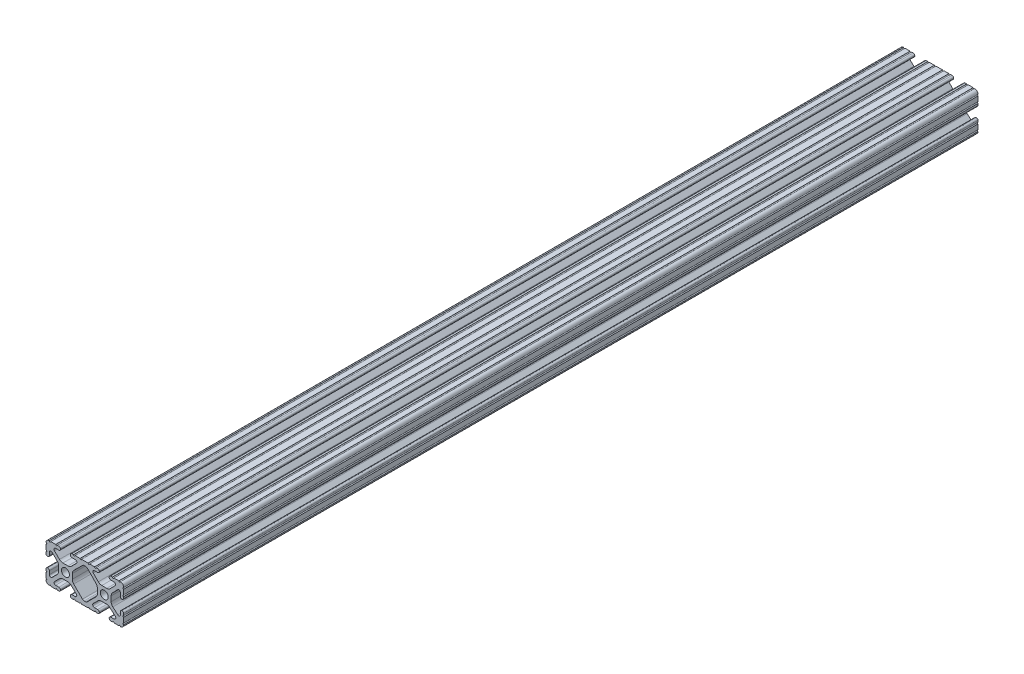
from build123d import *

# Parameters (mm, degrees)
SKETCH1_R               = 2.6035
BOSS_EXTRUDE1_DEPTH     = 279.4
SKETCH2_R               = 3.175
CUT_EXTRUDE1_DEPTH      = 9.2042
CUT_EXTRUDE1_DEPTH_BACK = 18.1958


with BuildPart() as part:
    # Sketch1 → Boss-Extrude1 (new body, symmetric)
    with BuildSketch(Plane.XY):
        with BuildLine():
            Line((18.01710265, 12.7), (16.98745015, 12.7))
            ThreePointArc((16.98745015, 12.7), (16.245730386, 12.392769614), (15.9385, 11.65104985))
            Line((15.9385, 11.65104985), (15.9385, 11.53922))
            ThreePointArc((15.9385, 11.53922), (16.245750844, 10.797450844), (16.98752, 10.4902))
            Line((16.98752, 10.4902), (19.116384363, 10.4902))
            ThreePointArc((19.116384363, 10.4902), (20.052502933, 9.869096983), (19.844087081, 8.765172272))
            Line((19.844087081, 8.765172272), (16.618993479, 5.455112286))
            ThreePointArc((16.618993479, 5.455112286), (15.578994274, 4.745442459), (14.344932584, 4.4958))
            Line((14.344932584, 4.4958), (11.083317835, 4.4958))
            ThreePointArc((11.083317835, 4.4958), (9.854330953, 4.743306833), (8.816955189, 5.447238587))
            Line((8.816955189, 5.447238587), (5.564154119, 8.762652677))
            ThreePointArc((5.564154119, 8.762652677), (5.352591412, 9.867473037), (6.289393385, 10.4902))
            Line((6.289393385, 10.4902), (8.41248, 10.4902))
            ThreePointArc((8.41248, 10.4902), (9.154249156, 10.797450844), (9.4615, 11.53922))
            Line((9.4615, 11.53922), (9.4615, 11.65104985))
            ThreePointArc((9.4615, 11.65104985), (9.154269614, 12.392769614), (8.41254985, 12.7))
            Line((8.41254985, 12.7), (7.38288465, 12.7))
            ThreePointArc((7.38288465, 12.7), (6.87488465, 12.192), (6.36688465, 12.7))
            Line((6.36688465, 12.7), (3.14958095, 12.7))
            ThreePointArc((3.14958095, 12.7), (2.64158095, 12.192), (2.13358095, 12.7))
            Line((2.13358095, 12.7), (-2.13358095, 12.7))
            ThreePointArc((-2.13358095, 12.7), (-2.64158095, 12.192), (-3.14958095, 12.7))
            Line((-3.14958095, 12.7), (-6.36689735, 12.7))
            ThreePointArc((-6.36689735, 12.7), (-6.87489735, 12.192), (-7.38289735, 12.7))
            Line((-7.38289735, 12.7), (-8.41254985, 12.7))
            ThreePointArc((-8.41254985, 12.7), (-9.154269614, 12.392769614), (-9.4615, 11.65104985))
            Line((-9.4615, 11.65104985), (-9.4615, 11.53922))
            ThreePointArc((-9.4615, 11.53922), (-9.154249156, 10.797450844), (-8.41248, 10.4902))
            Line((-8.41248, 10.4902), (-6.283641037, 10.4902))
            ThreePointArc((-6.283641037, 10.4902), (-5.297291557, 9.829633109), (-5.532576693, 8.666071843))
            Line((-5.532576693, 8.666071843), (-8.809985098, 5.416263103))
            ThreePointArc((-8.809985098, 5.416263103), (-9.836720513, 4.734920264), (-11.045536121, 4.4958))
            Line((-11.045536121, 4.4958), (-14.354463879, 4.4958))
            ThreePointArc((-14.354463879, 4.4958), (-15.563279487, 4.734920264), (-16.590014902, 5.416263103))
            Line((-16.590014902, 5.416263103), (-19.867423307, 8.666071843))
            ThreePointArc((-19.867423307, 8.666071843), (-20.102708443, 9.829633109), (-19.116358963, 10.4902))
            Line((-19.116358963, 10.4902), (-16.98752, 10.4902))
            ThreePointArc((-16.98752, 10.4902), (-16.245750844, 10.797450844), (-15.9385, 11.53922))
            Line((-15.9385, 11.53922), (-15.9385, 11.65104985))
            ThreePointArc((-15.9385, 11.65104985), (-16.245730386, 12.392769614), (-16.98745015, 12.7))
            Line((-16.98745015, 12.7), (-18.01711535, 12.7))
            ThreePointArc((-18.01711535, 12.7), (-18.52511535, 12.192), (-19.03311535, 12.7))
            Line((-19.03311535, 12.7), (-22.2504, 12.7))
            ThreePointArc((-22.2504, 12.7), (-22.758323491, 12.192000006), (-23.266399977, 12.699846982))
            ThreePointArc((-23.266399977, 12.699846982), (-24.782522516, 12.082522516), (-25.399846982, 10.566399977))
            ThreePointArc((-25.399846982, 10.566399977), (-24.892000006, 10.058323491), (-25.4, 9.5504))
            Line((-25.4, 9.5504), (-25.4, 6.3330836))
            ThreePointArc((-25.4, 6.3330836), (-24.892, 5.8250836), (-25.4, 5.3170836))
            Line((-25.4, 5.3170836), (-25.4, 4.237520184))
            ThreePointArc((-25.4, 4.237520184), (-25.107393763, 3.531106237), (-24.400979816, 3.2385))
            Line((-24.400979816, 3.2385), (-24.23922, 3.2385))
            ThreePointArc((-24.23922, 3.2385), (-23.497450844, 3.545750844), (-23.1902, 4.28752))
            Line((-23.1902, 4.28752), (-23.1902, 6.334741132))
            ThreePointArc((-23.1902, 6.334741132), (-22.556026952, 7.286023527), (-21.434002553, 7.066535717))
            Line((-21.434002553, 7.066535717), (-18.147950853, 3.808156468))
            ThreePointArc((-18.147950853, 3.808156468), (-17.452759693, 2.774838327), (-17.208501877, 1.553619571))
            Line((-17.208501877, 1.553619571), (-17.208501877, -1.695179196))
            ThreePointArc((-17.208501877, -1.695179196), (-17.450738657, -2.911536421), (-18.140486065, -3.942289578))
            Line((-18.140486065, -3.942289578), (-21.431579576, -7.227386226))
            ThreePointArc((-21.431579576, -7.227386226), (-22.55444896, -7.449940594), (-23.1902, -6.498002195))
            Line((-23.1902, -6.498002195), (-23.1902, -4.28752))
            ThreePointArc((-23.1902, -4.28752), (-23.497450844, -3.545750844), (-24.23922, -3.2385))
            Line((-24.23922, -3.2385), (-24.35098, -3.2385))
            ThreePointArc((-24.35098, -3.2385), (-25.092749156, -3.545750844), (-25.4, -4.28752))
            Line((-25.4, -4.28752), (-25.4, -5.3171344))
            ThreePointArc((-25.4, -5.3171344), (-24.892, -5.8251344), (-25.4, -6.3331344))
            Line((-25.4, -6.3331344), (-25.4, -9.5504))
            ThreePointArc((-25.4, -9.5504), (-24.892000006, -10.058323491), (-25.399846982, -10.566399977))
            ThreePointArc((-25.399846982, -10.566399977), (-24.782522516, -12.082522516), (-23.266399977, -12.699846982))
            ThreePointArc((-23.266399977, -12.699846982), (-22.758323491, -12.192000006), (-22.2504, -12.7))
            Line((-22.2504, -12.7), (-19.03308995, -12.7))
            ThreePointArc((-19.03308995, -12.7), (-18.52508995, -12.192), (-18.01708995, -12.7))
            Line((-18.01708995, -12.7), (-16.9874692, -12.7))
            ThreePointArc((-16.9874692, -12.7), (-16.245700044, -12.392749156), (-15.9384492, -11.65098))
            Line((-15.9384492, -11.65098), (-15.9384492, -11.53922))
            ThreePointArc((-15.9384492, -11.53922), (-16.245700044, -10.797450844), (-16.9874692, -10.4902))
            Line((-16.9874692, -10.4902), (-19.116358963, -10.4902))
            ThreePointArc((-19.116358963, -10.4902), (-20.055197748, -9.862578342), (-19.834124023, -8.755124678))
            Line((-19.834124023, -8.755124678), (-16.49660751, -5.423689618))
            ThreePointArc((-16.49660751, -5.423689618), (-15.467274017, -4.736928798), (-14.253591699, -4.4958))
            Line((-14.253591699, -4.4958), (-11.146408301, -4.4958))
            ThreePointArc((-11.146408301, -4.4958), (-9.932725983, -4.736928798), (-8.90339249, -5.423689618))
            Line((-8.90339249, -5.423689618), (-5.565875977, -8.755124678))
            ThreePointArc((-5.565875977, -8.755124678), (-5.344802252, -9.862578342), (-6.283641037, -10.4902))
            Line((-6.283641037, -10.4902), (-8.4125308, -10.4902))
            ThreePointArc((-8.4125308, -10.4902), (-9.154299956, -10.797450844), (-9.4615508, -11.53922))
            Line((-9.4615508, -11.53922), (-9.4615508, -11.65098))
            ThreePointArc((-9.4615508, -11.65098), (-9.154299956, -12.392749156), (-8.4125308, -12.7))
            Line((-8.4125308, -12.7), (-7.38287195, -12.7))
            ThreePointArc((-7.38287195, -12.7), (-6.87487195, -12.192), (-6.36687195, -12.7))
            Line((-6.36687195, -12.7), (-3.14960635, -12.7))
            ThreePointArc((-3.14960635, -12.7), (-2.64160635, -12.192), (-2.13360635, -12.7))
            Line((-2.13360635, -12.7), (2.13360635, -12.7))
            ThreePointArc((2.13360635, -12.7), (2.64159365, -12.1920127), (3.14958095, -12.7))
            Line((3.14958095, -12.7), (6.36691005, -12.7))
            ThreePointArc((6.36691005, -12.7), (6.87491005, -12.192), (7.38291005, -12.7))
            Line((7.38291005, -12.7), (8.4125308, -12.7))
            ThreePointArc((8.4125308, -12.7), (9.154299956, -12.392749156), (9.4615508, -11.65098))
            Line((9.4615508, -11.65098), (9.4615508, -11.53922))
            ThreePointArc((9.4615508, -11.53922), (9.154299956, -10.797450844), (8.4125308, -10.4902))
            Line((8.4125308, -10.4902), (6.289393385, -10.4902))
            ThreePointArc((6.289393385, -10.4902), (5.231590322, -9.783049717), (5.480677245, -8.535265862))
            Line((5.480677245, -8.535265862), (8.597933595, -5.423689618))
            ThreePointArc((8.597933595, -5.423689618), (9.627267088, -4.736928798), (10.840949406, -4.4958))
            Line((10.840949406, -4.4958), (14.102564155, -4.4958))
            ThreePointArc((14.102564155, -4.4958), (15.215927525, -4.697410182), (16.187895372, -5.276636531))
            Line((16.187895372, -5.276636531), (19.868247549, -8.482246082))
            ThreePointArc((19.868247549, -8.482246082), (20.188435806, -9.746879864), (19.116384363, -10.4902))
            Line((19.116384363, -10.4902), (16.9874692, -10.4902))
            ThreePointArc((16.9874692, -10.4902), (16.245700044, -10.797450844), (15.9384492, -11.53922))
            Line((15.9384492, -11.53922), (15.9384492, -11.65098))
            ThreePointArc((15.9384492, -11.65098), (16.245700044, -12.392749156), (16.9874692, -12.7))
            Line((16.9874692, -12.7), (18.01710265, -12.7))
            ThreePointArc((18.01710265, -12.7), (18.52510265, -12.192), (19.03310265, -12.7))
            Line((19.03310265, -12.7), (22.2504, -12.7))
            ThreePointArc((22.2504, -12.7), (22.758323491, -12.192000006), (23.266399977, -12.699846982))
            ThreePointArc((23.266399977, -12.699846982), (24.782522516, -12.082522516), (25.399846982, -10.566399977))
            ThreePointArc((25.399846982, -10.566399977), (24.892000006, -10.058323492), (25.4, -9.550400001))
            Line((25.4, -9.550400001), (25.4, -6.333083592))
            ThreePointArc((25.4, -6.333083592), (24.892000001, -5.825083593), (25.4, -5.317083593))
            Line((25.4, -5.317083593), (25.4, -4.237520184))
            ThreePointArc((25.4, -4.237520184), (25.107393763, -3.531106237), (24.400979816, -3.2385))
            Line((24.400979816, -3.2385), (24.189220184, -3.2385))
            ThreePointArc((24.189220184, -3.2385), (23.482806237, -3.531106237), (23.1902, -4.237520184))
            Line((23.1902, -4.237520184), (23.1902, -6.155876159))
            ThreePointArc((23.1902, -6.155876159), (22.62232736, -7.038258539), (21.583974541, -6.886926384))
            Line((21.583974541, -6.886926384), (18.29817066, -4.024970844))
            ThreePointArc((18.29817066, -4.024970844), (17.493730985, -2.946044689), (17.208501877, -1.630807374))
            Line((17.208501877, -1.630807374), (17.208501877, 1.630807374))
            ThreePointArc((17.208501877, 1.630807374), (17.442348332, 2.82673414), (18.109440981, 3.846495088))
            Line((18.109440981, 3.846495088), (21.526346532, 7.353420386))
            ThreePointArc((21.526346532, 7.353420386), (22.585896263, 7.574939077), (23.1902, 6.676867167))
            Line((23.1902, 6.676867167), (23.1902, 4.237520184))
            ThreePointArc((23.1902, 4.237520184), (23.482806237, 3.531106237), (24.189220184, 3.2385))
            Line((24.189220184, 3.2385), (24.400979816, 3.2385))
            ThreePointArc((24.400979816, 3.2385), (25.107393763, 3.531106237), (25.4, 4.237520184))
            Line((25.4, 4.237520184), (25.4, 5.3170836))
            ThreePointArc((25.4, 5.3170836), (24.891949193, 5.825134407), (25.4, 6.333185215))
            Line((25.4, 6.333185215), (25.4, 9.550400015))
            ThreePointArc((25.4, 9.550400015), (24.892000013, 10.058323498), (25.399846982, 10.566399977))
            ThreePointArc((25.399846982, 10.566399977), (24.782522516, 12.082522516), (23.266399977, 12.699846982))
            ThreePointArc((23.266399977, 12.699846982), (22.758323491, 12.192000006), (22.2504, 12.7))
            Line((22.2504, 12.7), (19.03310265, 12.7))
            ThreePointArc((19.03310265, 12.7), (18.52510265, 12.192), (18.01710265, 12.7))
        make_face()
        with Locations((-12.7, 0)):
            Circle(SKETCH1_R, mode=Mode.SUBTRACT)
        with Locations((12.7, 0)):
            Circle(SKETCH1_R, mode=Mode.SUBTRACT)
        with BuildLine():
            Line((-7.259513935, -3.869413038), (-1.545748891, -9.572766749))
            ThreePointArc((-1.545748891, -9.572766749), (-1.035199478, -9.913400116), (-0.433213048, -10.033))
            Line((-0.433213048, -10.033), (0.433213048, -10.033))
            ThreePointArc((0.433213048, -10.033), (1.035199478, -9.913400116), (1.545748891, -9.572766749))
            Line((1.545748891, -9.572766749), (7.259513935, -3.869413038))
            ThreePointArc((7.259513935, -3.869413038), (7.949261343, -2.838659881), (8.191498123, -1.622302656))
            Line((8.191498123, -1.622302656), (8.191498123, 1.622302656))
            ThreePointArc((8.191498123, 1.622302656), (7.955573352, 2.823327967), (7.282860769, 3.845864069))
            Line((7.282860769, 3.845864069), (1.675572808, 9.561086461))
            ThreePointArc((1.675572808, 9.561086461), (1.161034429, 9.910236611), (0.551456936, 10.033))
            Line((0.551456936, 10.033), (-0.395199982, 10.033))
            ThreePointArc((-0.395199982, 10.033), (-0.994772524, 9.914396349), (-1.50403329, 9.576450301))
            Line((-1.50403329, 9.576450301), (-7.252049147, 3.876839553))
            ThreePointArc((-7.252049147, 3.876839553), (-7.947240307, 2.843521412), (-8.191498123, 1.622302656))
            Line((-8.191498123, 1.622302656), (-8.191498123, -1.622302656))
            ThreePointArc((-8.191498123, -1.622302656), (-7.949261343, -2.838659881), (-7.259513935, -3.869413038))
        make_face(mode=Mode.SUBTRACT)
    extrude(amount=BOSS_EXTRUDE1_DEPTH, both=True)

    # Sketch2 → Cut-Extrude1 (cut, two sides)
    with BuildSketch(Plane(origin=(0, 4.4958, 0), x_dir=(1, 0, 0), z_dir=(0, 1, 0))) as cut_extrude1_sk:
        with Locations((-12.7, -254)):
            Circle(SKETCH2_R)
        with Locations((-12.7, 254)):
            Circle(SKETCH2_R)
        with Locations((12.7, 254)):
            Circle(SKETCH2_R)
        with Locations((12.7, -254)):
            Circle(SKETCH2_R)
    extrude(amount=CUT_EXTRUDE1_DEPTH, mode=Mode.SUBTRACT)
    extrude(cut_extrude1_sk.sketch, amount=-CUT_EXTRUDE1_DEPTH_BACK, mode=Mode.SUBTRACT)


solid = part.part
